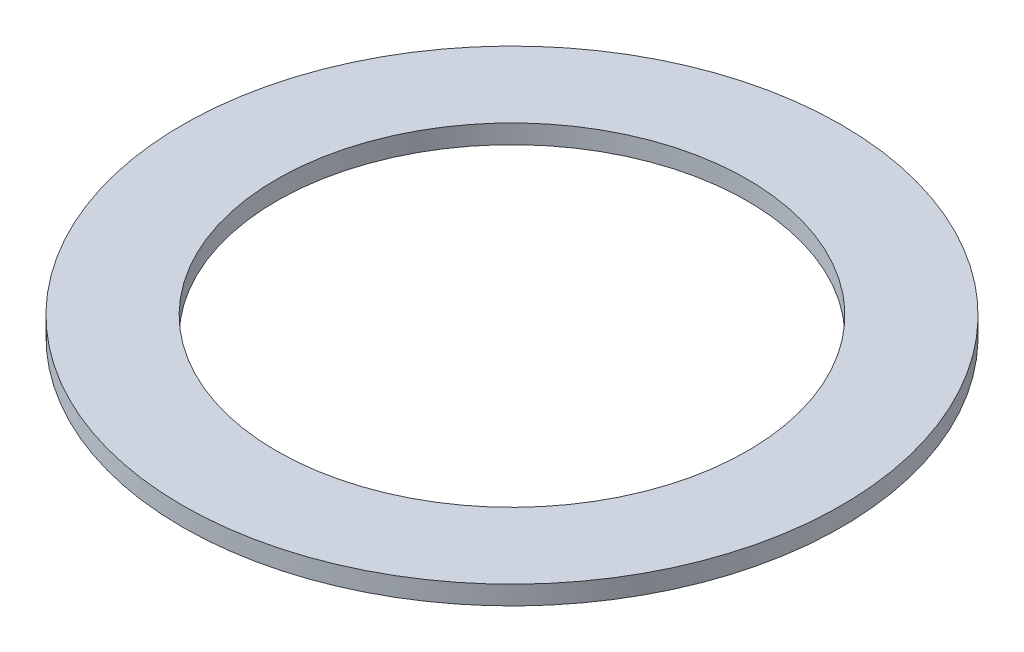
from build123d import *

# Parameters (mm, degrees)
SKETCH1_R           = 3.5
BOSS_EXTRUDE1_DEPTH = 0.2
SKETCH5_R           = 2.5
CUT_EXTRUDE1_DEPTH  = 1.2


with BuildPart() as part:
    # Sketch1 → Boss-Extrude1 (new body)
    with BuildSketch(Plane(origin=(0, 0, 0), x_dir=(1, 0, 0), z_dir=(0, 1, 0))):
        Circle(SKETCH1_R)
    extrude(amount=BOSS_EXTRUDE1_DEPTH)

    # Sketch5 → Cut-Extrude1 (cut, through all)
    with BuildSketch(Plane(origin=(0, 0.2, 0), x_dir=(-1, 0, 0), z_dir=(0, 1, 0))):
        Circle(SKETCH5_R)
    extrude(amount=-CUT_EXTRUDE1_DEPTH, mode=Mode.SUBTRACT)


solid = part.part
